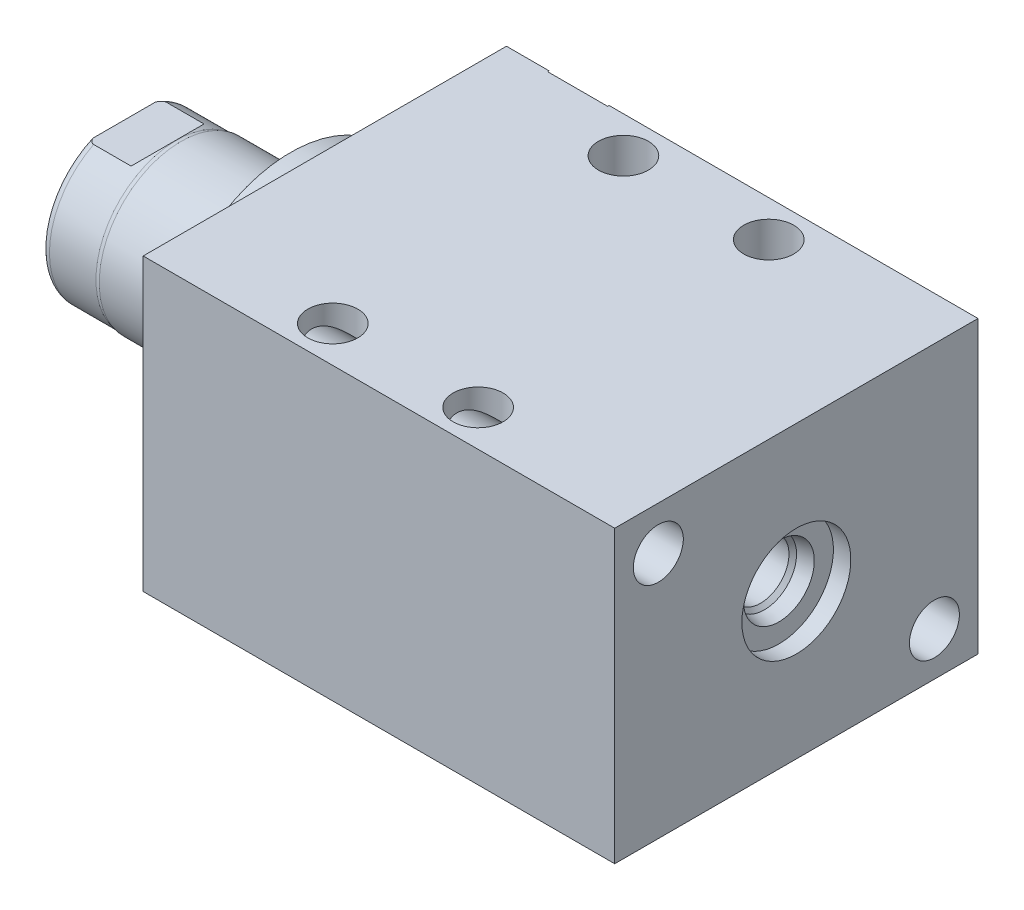
from build123d import *

# Parameters (mm, degrees)
SKETCH1_W          = 63.5
SKETCH1_H          = 50.8
EXTRUDE1_DEPTH     = 82.423
SKETCH5_R          = 22.225
EXTRUDE2_DEPTH     = 5.969
SKETCH6_W          = 14.2875
SKETCH6_H          = 29.083
CUT_EXTRUDE4_DEPTH = 30.48
HOLE1_D            = 8.7376
HOLE1_DEPTH        = 82.423
HOLE2_D            = 8.7376
HOLE2_DEPTH        = 50.8
LPATTERN1_COUNT    = 2
LPATTERN1_PITCH    = 25.4


with BuildPart() as part:
    # Sketch1 → Extrude1 (new body)
    with BuildSketch(Plane(origin=(0, 0, 0), x_dir=(0, 0, -1), z_dir=(1, 0, 0))):
        Rectangle(SKETCH1_W, SKETCH1_H)
    extrude(amount=EXTRUDE1_DEPTH)

    # S2D0002 → Cut-Revolve1 (revolve, cut)
    with BuildSketch(Plane(origin=(0, 17.4498, 0), x_dir=(-1, 0, 0), z_dir=(0, 1, 0)), mode=Mode.PRIVATE) as cut_revolve1_sk:
        Polygon((-18.8849, -31.496), (-22.225, -31.496), (-22.225, -31.75), (-12.7, -31.75), (-12.7, -17.526), (-17.6784, -17.526), (-17.6784, -28.279393135), (-18.342306865, -28.9433), align=None)
    revolve(cut_revolve1_sk.sketch.rotate(Axis((12.7, 17.4498, -19.13842003), (0, 0, 1)), 180), axis=Axis((12.7, 17.4498, -19.13842003), (0, 0, 1)), mode=Mode.SUBTRACT)  # turned: the seam where the file's is

    # Sketch3 → Cut-Revolve2 (revolve, cut)
    with BuildSketch(Plane(origin=(41.148, 0, -25.146), x_dir=(1, 0, 0), z_dir=(0, 1, 0))):
        Polygon((31.5849, 6.35), (34.925, 6.35), (34.925, 6.604), (25.4, 6.604), (25.4, -7.62), (30.3784, -7.62), (30.3784, 3.133393135), (31.042306865, 3.7973), align=None)
    revolve(axis=Axis((66.548, 0, -3.189624441), (0, 0, -1)), mode=Mode.SUBTRACT)

    # Sketch4 → Cut-Revolve3 (revolve, cut)
    with BuildSketch(Plane(origin=(53.975, 0, 0), x_dir=(0, -1, 0), z_dir=(0, 0, 1)), mode=Mode.PRIVATE) as cut_revolve3_sk:
        Polygon((6.1849, 25.4), (9.525, 25.4), (9.525, 28.448), (0, 28.448), (0, 14.0462), (4.9784, 14.0462), (4.9784, 22.183393135), (5.642306865, 22.8473), align=None)
    revolve(cut_revolve3_sk.sketch.rotate(Axis((38.879609832, 0, 0), (1, 0, 0)), 270), axis=Axis((38.879609832, 0, 0), (1, 0, 0)), mode=Mode.SUBTRACT)  # turned: the seam where the file's is

    # Sketch5 → Extrude2 (add)
    with BuildSketch(Plane.ZY):
        Circle(SKETCH5_R)
    extrude(amount=EXTRUDE2_DEPTH)

    # Sketch6 → Revolve1 (revolve)
    with BuildSketch(Plane(origin=(0, 0, 0), x_dir=(0, 0, 1), z_dir=(0, -1, 0)), mode=Mode.PRIVATE) as revolve1_sk:
        with Locations((-7.14375, 20.5105)):
            Rectangle(SKETCH6_W, SKETCH6_H)
    revolve(revolve1_sk.sketch.rotate(Axis((5.754582971, 0, 0), (-1, 0, 0)), 180), axis=Axis((5.754582971, 0, 0), (-1, 0, 0)))  # turned: the seam where the file's is

    # S2D0001 → Cut-Revolve4 (revolve, cut)
    with BuildSketch(Plane(origin=(-18.511260017, 3.2639, 0), x_dir=(0, 1, 0), z_dir=(0, 0, 1)), mode=Mode.PRIVATE) as cut_revolve4_sk:
        Polygon((2.286, 14.473017728), (2.286, -1.950460017), (-3.2639, -1.950460017), (-3.2639, 16.540739983), (3.4798, 16.540739983), align=None)
    revolve(cut_revolve4_sk.sketch.rotate(Axis((0, 0, 0), (-1, 0, 0)), 270), axis=Axis((0, 0, 0), (-1, 0, 0)), mode=Mode.SUBTRACT)  # turned: the seam where the file's is

    # Sketch8 → Cut-Revolve5 (revolve, cut)
    with BuildSketch(Plane(origin=(0, 0, 0), x_dir=(0, 0, -1), z_dir=(0, 1, 0)), mode=Mode.PRIVATE) as cut_revolve5_sk:
        with BuildLine():
            Line((-14.2875, 25.146), (-14.097, 25.908))
            Line((-14.097, 25.908), (-14.097, 34.036))
            ThreePointArc((-14.097, 34.036), (-13.996678675, 34.579796865), (-13.708922533, 35.052))
            Line((-13.708922533, 35.052), (-14.2875, 35.052))
            Line((-14.2875, 35.052), (-14.2875, 25.146))
        make_face()
    revolve(cut_revolve5_sk.sketch.rotate(Axis((-12.65936, 0, 0), (-1, 0, 0)), 180), axis=Axis((-12.65936, 0, 0), (-1, 0, 0)), mode=Mode.SUBTRACT)  # turned: the seam where the file's is

    # Sketch12 → Cut-Extrude4 (cut, symmetric)
    with BuildSketch(Plane(origin=(0, 0, 0), x_dir=(0, -1, 0), z_dir=(0, 0, -1))):
        Polygon((12.573, 35.052), (12.573, 27.4828), (14.097, 25.9588), (14.097, 35.052), align=None)
        Polygon((-12.573, 35.052), (-12.573, 27.4828), (-14.097, 25.9588), (-14.097, 35.052), align=None)
    extrude(amount=CUT_EXTRUDE4_DEPTH, both=True, mode=Mode.SUBTRACT)

    # Hole1
    with Locations(Plane.ZY):
        with Locations((-24.13, -17.78), (24.13, 17.78)):
            Hole(HOLE1_D / 2, depth=HOLE1_DEPTH)

    # Hole2
    with Locations(Plane(origin=(0, 25.4, 0), x_dir=(-1, 0, 0), z_dir=(0, 1, 0))):
        with Locations((-26.797, -25.4), (-26.797, 25.4)):
            hole2 = Hole(HOLE2_D / 2, depth=HOLE2_DEPTH)

    # LPattern1: Hole2 ×2
    with Locations(*[(i * LPATTERN1_PITCH, 0, 0) for i in range(1, LPATTERN1_COUNT)]):
        add(hole2, mode=Mode.SUBTRACT)


solid = part.part
